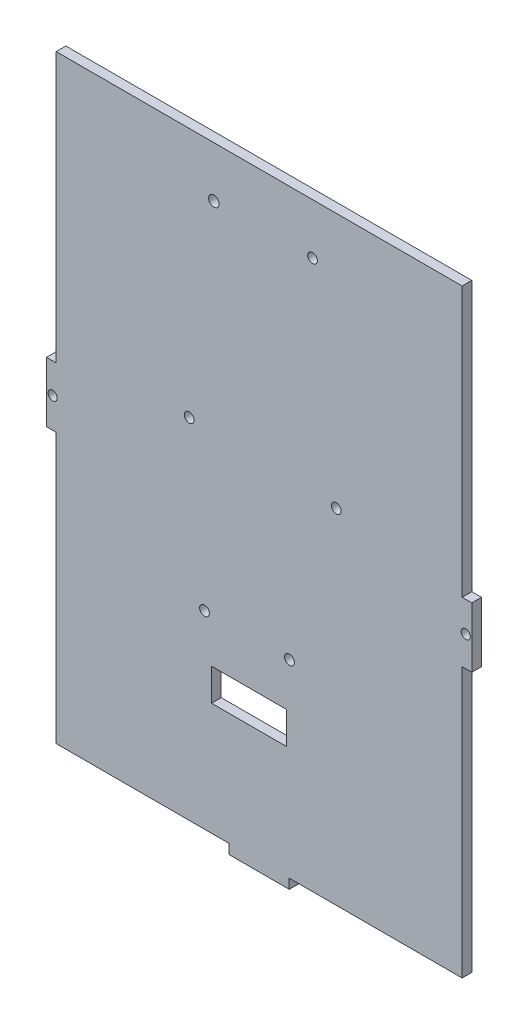
from build123d import *

# Parameters (mm, degrees)
SKETCH1_W           = 139.7
SKETCH1_H           = 203.2
BOSS_EXTRUDE1_DEPTH = 3.18
SKETCH2_R           = 1.5
SKETCH2_W           = 3.18
SKETCH2_H           = 91.725
CUT_EXTRUDE1_DEPTH  = 4.18
SKETCH3_R           = 1.59
CUT_EXTRUDE2_DEPTH  = 4.18
SKETCH4_R           = 1.59
CUT_EXTRUDE3_DEPTH  = 4.18
SKETCH5_W           = 88.895716174
SKETCH5_H           = 168.56277979
BOSS_EXTRUDE2_DEPTH = 3.18
SKETCH6_W           = 20
SKETCH6_H           = 203.2
BOSS_EXTRUDE3_DEPTH = 3.18
SKETCH7_W           = 56.795
SKETCH7_H           = 3.18
CUT_EXTRUDE4_DEPTH  = 4.18
SKETCH8_W           = 133.34
SKETCH8_H           = 3.18
CUT_EXTRUDE5_DEPTH  = 4.18
SKETCH9_R           = 1.6
CUT_EXTRUDE6_DEPTH  = 4.18
SKETCH10_W          = 24.565797096
SKETCH10_H          = 10.537213664
CUT_EXTRUDE7_DEPTH  = 3.18
SKETCH11_R          = 1.59
SKETCH11_R_2        = 1.71788268
CUT_EXTRUDE8_DEPTH  = 35


with BuildPart() as part:
    # Sketch1 → Boss-Extrude1 (new body)
    with BuildSketch(Plane.XY):
        Rectangle(SKETCH1_W, SKETCH1_H)
    extrude(amount=BOSS_EXTRUDE1_DEPTH)

    # Sketch2 → Cut-Extrude1 (cut, through all)
    with BuildSketch(Plane.XY.offset(3.18)):
        with Locations((-67.85, 0)):
            Circle(SKETCH2_R)
        with Locations((67.85, 0)):
            Circle(SKETCH2_R)
        Polygon((-10, 101.6), (10, 101.6), (10, 98.42), (1.5, 98.42), (1.5, 94.42), (3.5, 94.42), (3.5, 91.42), (1.5, 91.42), (1.5, 88.42), (-1.5, 88.42), (-1.5, 91.42), (-3.5, 91.42), (-3.5, 94.42), (-1.5, 94.42), (-1.5, 98.42), (-10, 98.42), align=None)
        Polygon((-10, -101.6), (-10, -98.42), (-1.5, -98.42), (-1.5, -94.42), (-3.5, -94.42), (-3.5, -91.42), (-1.5, -91.42), (-1.5, -88.42), (1.5, -88.42), (1.5, -91.42), (3.5, -91.42), (3.5, -94.42), (1.5, -94.42), (1.5, -98.42), (10, -98.42), (10, -101.6), align=None)
        with Locations((-68.26, 55.7375)):
            Rectangle(SKETCH2_W, SKETCH2_H)
        with Locations((-68.26, -55.7375)):
            Rectangle(SKETCH2_W, SKETCH2_H)
        with Locations((68.26, -55.7375)):
            Rectangle(SKETCH2_W, SKETCH2_H)
        with Locations((68.26, 55.7375)):
            Rectangle(SKETCH2_W, SKETCH2_H)
    extrude(amount=-CUT_EXTRUDE1_DEPTH, mode=Mode.SUBTRACT)

    # Sketch3 → Cut-Extrude2 (cut, through all)
    with BuildSketch(Plane(origin=(0, 0, 0), x_dir=(-1, 0, 0), z_dir=(0, 0, -1))):
        with Locations((-35.67127699, -47.963396943)):
            Circle(SKETCH3_R)
        with Locations((-35.67127699, -30.777287406)):
            Circle(SKETCH3_R)
    extrude(amount=-CUT_EXTRUDE2_DEPTH, mode=Mode.SUBTRACT)

    # Sketch4 → Cut-Extrude3 (cut, through all)
    with BuildSketch(Plane(origin=(0, 0, 0), x_dir=(-1, 0, 0), z_dir=(0, 0, -1))):
        with Locations((-34.750723073, 80.736128989)):
            Circle(SKETCH4_R)
        with Locations((-34.750723073, 63.550019452)):
            Circle(SKETCH4_R)
        with Locations((36.249784221, 80.736128989)):
            Circle(SKETCH4_R)
        with Locations((36.249784221, 63.550019452)):
            Circle(SKETCH4_R)
        with Locations((35.983928162, -30.777287406)):
            Circle(SKETCH4_R)
        with Locations((35.983928162, -47.963396943)):
            Circle(SKETCH4_R)
        with Locations((-35.67127699, -30.777287406)):
            Circle(SKETCH4_R)
        with Locations((-35.67127699, -47.963396943)):
            Circle(SKETCH4_R)
    extrude(amount=-CUT_EXTRUDE3_DEPTH, mode=Mode.SUBTRACT)

    # Sketch5 → Boss-Extrude2 (add)
    with BuildSketch(Plane.XY.offset(3.18)):
        Rectangle(SKETCH5_W, SKETCH5_H)
    extrude(amount=-BOSS_EXTRUDE2_DEPTH)

    # Sketch6 → Boss-Extrude3 (add)
    with BuildSketch(Plane.XY.offset(3.18)):
        Rectangle(SKETCH6_W, SKETCH6_H)
    extrude(amount=-BOSS_EXTRUDE3_DEPTH)

    # Sketch7 → Cut-Extrude4 (cut, through all)
    with BuildSketch(Plane.XY.offset(3.18)):
        with Locations((-38.2725, -100.01)):
            Rectangle(SKETCH7_W, SKETCH7_H)
        with Locations((38.2725, -100.01)):
            Rectangle(SKETCH7_W, SKETCH7_H)
    extrude(amount=-CUT_EXTRUDE4_DEPTH, mode=Mode.SUBTRACT)

    # Sketch8 → Cut-Extrude5 (cut, through all)
    with BuildSketch(Plane.XY.offset(3.18)):
        with Locations((0, 100.01)):
            Rectangle(SKETCH8_W, SKETCH8_H)
    extrude(amount=-CUT_EXTRUDE5_DEPTH, mode=Mode.SUBTRACT)

    # Sketch9 → Cut-Extrude6 (cut, through all)
    with BuildSketch(Plane.XY.offset(3.18)):
        with Locations((-17.947926552, -36.205077673)):
            Circle(SKETCH9_R)
        with Locations((25.333125389, 14.525884697)):
            Circle(SKETCH9_R)
        with Locations((-22.964258499, 16.202998173)):
            Circle(SKETCH9_R)
        with Locations((9.952037888, -36.24962266)):
            Circle(SKETCH9_R)
    extrude(amount=-CUT_EXTRUDE6_DEPTH, mode=Mode.SUBTRACT)

    # Sketch10 → Cut-Extrude7 (cut)
    with BuildSketch(Plane.XY.offset(3.18)):
        with Locations((-3.359789788, -56.149532718)):
            Rectangle(SKETCH10_W, SKETCH10_H)
    extrude(amount=-CUT_EXTRUDE7_DEPTH, mode=Mode.SUBTRACT)

    # Sketch11 → Cut-Extrude8 (cut)
    with BuildSketch(Plane.XY.offset(3.18)):
        with Locations((17.523878239, 81.797398404)):
            Circle(SKETCH11_R)
        with Locations((-14.883091948, 81.797398404)):
            Circle(SKETCH11_R_2)
    extrude(amount=-CUT_EXTRUDE8_DEPTH, mode=Mode.SUBTRACT)


solid = part.part
